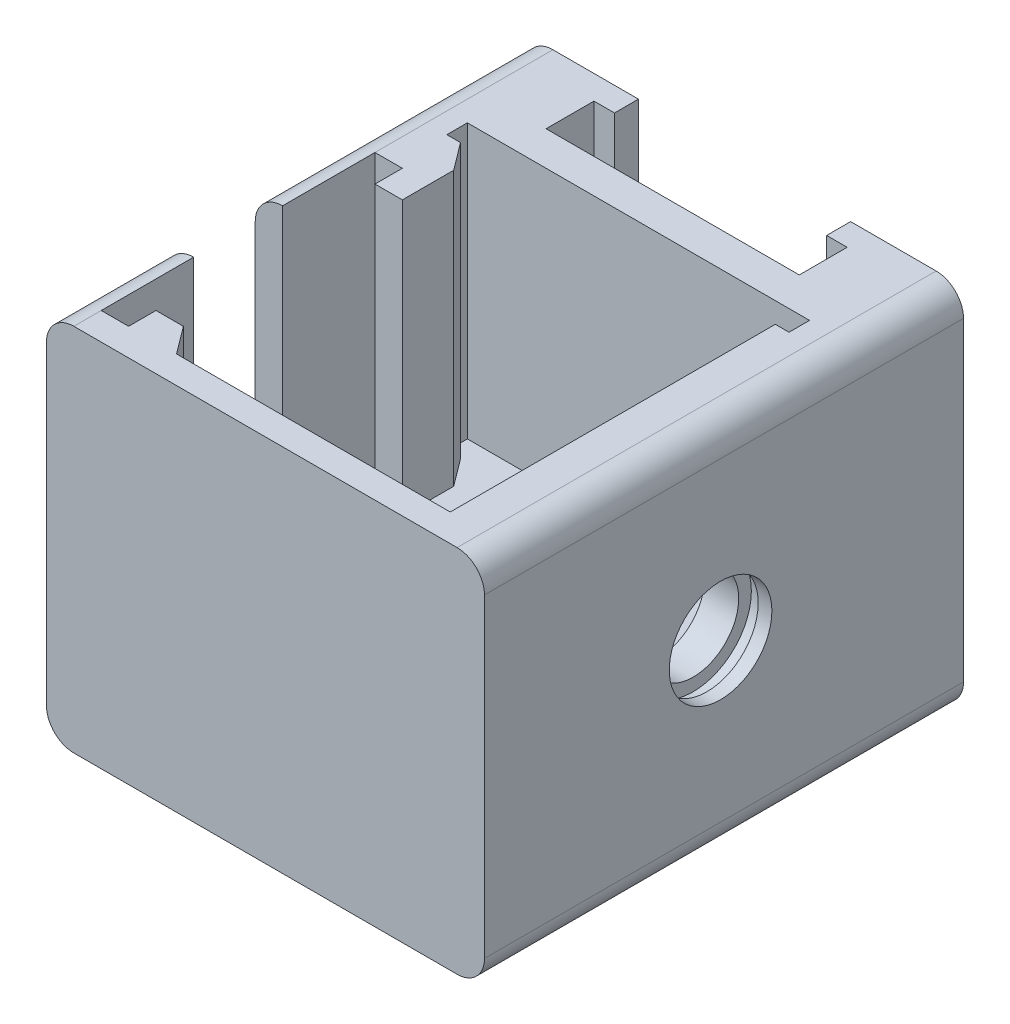
from build123d import *

# Parameters (mm, degrees)
SKETCH1_W               = 32
SKETCH1_H               = 27
BOSS_EXTRUDE1_DEPTH     = 35
FILLET1_R               = 2
CUT_EXTRUDE1_DEPTH      = 1
CUT_EXTRUDE1_DEPTH_BACK = 28
BOSS_EXTRUDE2_DEPTH     = 7
BOSS_EXTRUDE3_DEPTH     = 1.75
SKETCH5_W               = 2
SKETCH5_H               = 7
CUT_EXTRUDE2_DEPTH      = 33
CUT_EXTRUDE3_DEPTH      = 20
SKETCH7_W               = 2
SKETCH7_H               = 33
BOSS_EXTRUDE4_DEPTH     = 0.25
FILLET2_R               = 6
CUT_EXTRUDE5_DEPTH      = 4.5
SKETCH14_W              = 2.5
SKETCH14_H              = 20
CUT_EXTRUDE6_DEPTH      = 20
SKETCH16_W              = 2
SKETCH16_H              = 3.75
SKETCH16_H_2            = 2
BOSS_EXTRUDE5_DEPTH     = 20
BOSS_EXTRUDE6_DEPTH     = 20


with BuildPart() as part:
    # Sketch1 → Boss-Extrude1 (new body)
    with BuildSketch(Plane.XY):
        Rectangle(SKETCH1_W, SKETCH1_H)
    extrude(amount=BOSS_EXTRUDE1_DEPTH)

    # Fillet1
    fillet1_edges = [part.edges().sort_by_distance(p)[0] for p in [
        (16, -13.5, 17.5),
        (-16, -13.5, 17.5),
        (-16, 13.5, 17.5),
        (16, 13.5, 17.5),
    ]]
    fillet(fillet1_edges, radius=FILLET1_R)

    # Sketch2 → Cut-Extrude1 (cut, two sides)
    with BuildSketch(Plane.XZ.offset(13.5)) as cut_extrude1_sk:
        Polygon((-7.75, 0), (-7.75, 1.75), (-9.25, 1.75), (-9.25, 5.25), (9.25, 5.25), (9.25, 1.75), (7.75, 1.75), (7.75, 0), align=None)
    extrude(amount=CUT_EXTRUDE1_DEPTH, mode=Mode.SUBTRACT)
    extrude(cut_extrude1_sk.sketch, amount=-CUT_EXTRUDE1_DEPTH_BACK, mode=Mode.SUBTRACT)

    # Sketch3 → Boss-Extrude2 (add)
    with BuildSketch(Plane.XZ.offset(13.5)):
        Polygon((-7.75, 0), (-7.75, 1.75), (-9.25, 1.75), (-9.25, 5.25), (9.25, 5.25), (9.25, 1.75), (7.75, 1.75), (7.75, 0), align=None)
    extrude(amount=-BOSS_EXTRUDE2_DEPTH)

    # Sketch4 → Boss-Extrude3 (add)
    with BuildSketch(Plane(origin=(0, 0, 1.75), x_dir=(-1, 0, 0), z_dir=(0, 0, -1))):
        with BuildLine():
            Line((-7.75, 6.5), (-7.75, 5.5))
            ThreePointArc((-7.75, 5.5), (-7.5, 6), (-7.75, 6.5))
        make_face()
    boss_extrude3 = extrude(amount=BOSS_EXTRUDE3_DEPTH)

    # Mirror1: Boss-Extrude3 across plane
    add(boss_extrude3.mirror(Plane(origin=(0, 0, 0), x_dir=(0, 0, 1), z_dir=(1, 0, 0))))

    # Sketch5 → Cut-Extrude2 (cut)
    with BuildSketch(Plane(origin=(0, 0, 0), x_dir=(-1, 0, 0), z_dir=(0, 0, -1))):
        with Locations((0, -10)):
            Rectangle(SKETCH5_W, SKETCH5_H)
    extrude(amount=-CUT_EXTRUDE2_DEPTH, mode=Mode.SUBTRACT)

    # Sketch6 → Cut-Extrude3 (cut)
    with BuildSketch(Plane(origin=(0, 13.5, 0), x_dir=(1, 0, 0), z_dir=(0, 1, 0))):
        Polygon((-12.5, -7.75), (-12.5, -9.25), (-11.5, -9.25), (-11.5, -33), (11.5, -33), (11.5, -9.25), (12.5, -9.25), (12.5, -7.75), align=None)
    extrude(amount=-CUT_EXTRUDE3_DEPTH, mode=Mode.SUBTRACT)

    # Sketch7 → Boss-Extrude4 (add)
    with BuildSketch(Plane.XZ.offset(13.5)):
        with Locations((0, 16.5)):
            Rectangle(SKETCH7_W, SKETCH7_H)
    extrude(amount=-BOSS_EXTRUDE4_DEPTH)

    # Fillet2
    fillet2_edges = [part.edges().sort_by_distance(p)[0] for p in [
        (0, -13.25, 33),
    ]]
    fillet(fillet2_edges, radius=FILLET2_R)

    # Sketch9 → Cut-Revolve1 (revolve, cut)
    with BuildSketch(Plane(origin=(0, 0, 17.75), x_dir=(-1, 0, 0), z_dir=(0, 0, -1))):
        Polygon((-15, 4.25), (-14, 4.25), (-14, 3.325), (-11.5, 3.325), (-11.5, 0), (-16, 0), (-16, 3.75), (-15, 3.75), align=None)
    revolve(axis=Axis((16, 0, 17.75), (-1, 0, 0)), mode=Mode.SUBTRACT)

    # Sketch11 → Cut-Extrude5 (cut)
    with BuildSketch(Plane(origin=(-16, 0, 44), x_dir=(0, 0, -1), z_dir=(1, 0, 0))):
        with BuildLine():
            Line((24.25, 23), (24.25, 0))
            ThreePointArc((24.25, 0), (21, -3.25), (17.75, 0))
            Line((17.75, 0), (17.75, 23))
            ThreePointArc((17.75, 23), (21, 26.25), (24.25, 23))
        make_face()
    extrude(amount=CUT_EXTRUDE5_DEPTH, mode=Mode.SUBTRACT)

    # Sketch14 → Cut-Extrude6 (cut)
    with BuildSketch(Plane(origin=(0, 13.5, 0), x_dir=(1, 0, 0), z_dir=(0, 1, 0))):
        with Locations((-12.75, -23)):
            Rectangle(SKETCH14_W, SKETCH14_H)
    extrude(amount=-CUT_EXTRUDE6_DEPTH, mode=Mode.SUBTRACT)

    # Sketch16 → Boss-Extrude5 (add)
    with BuildSketch(Plane(origin=(0, 13.5, 0), x_dir=(1, 0, 0), z_dir=(0, 1, 0))):
        with Locations((-11, -13.125)):
            Rectangle(SKETCH16_W, SKETCH16_H)
        with Locations((-11, -32)):
            Rectangle(SKETCH16_W, SKETCH16_H_2)
    extrude(amount=-BOSS_EXTRUDE5_DEPTH)

    # Sketch20 → Boss-Extrude6 (add)
    with BuildSketch(Plane(origin=(0, 13.5, 0), x_dir=(1, 0, 0), z_dir=(0, 1, 0))):
        Polygon((-11.5, -9.25), (-10, -11.25), (-11.5, -11.25), align=None)
        Polygon((-10, -31), (-8.5, -33), (-10, -33), align=None)
    extrude(amount=-BOSS_EXTRUDE6_DEPTH)


solid = part.part
